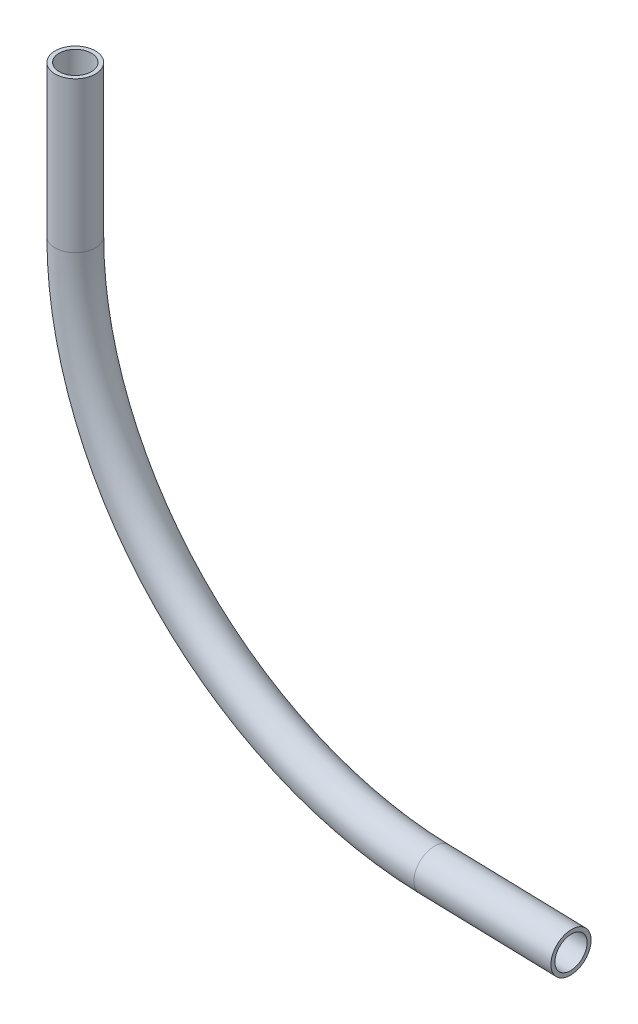
from build123d import *

# Parameters (mm, degrees)
SKETCH4_R           = 3.81
SKETCH4_R_2         = 3.048
BOSS_EXTRUDE1_DEPTH = 2.54
SKETCH4_3_R         = 3.81
SKETCH4_3_R_2       = 3.048


with BuildPart() as part:
    # Sketch4 → Boss-Extrude1 (new body)
    with BuildSketch(Plane(origin=(0, 110.370938621, 0), x_dir=(-1, 0, 0), z_dir=(0, 1, 0))):
        Circle(SKETCH4_R)
        Circle(SKETCH4_R_2, mode=Mode.SUBTRACT)
    extrude(amount=-BOSS_EXTRUDE1_DEPTH)

    # Sweep2: sweep along a path in Sketch3
    with BuildLine(Plane.XY) as sweep2_path:
        Line((0, 110.370938621), (0, 81.839949684))
        ThreePointArc((0, 81.839949684), (19.796310895, 33.11982338), (67.964229263, 12.015409809))
        Line((67.964229263, 12.015409809), (93.926499612, 11.314239564))
    # Sketch4_3 → Sweep2 (sweep)
    with BuildSketch(Plane(origin=(0, 110.370938621, 0), x_dir=(-1, 0, 0), z_dir=(0, 1, 0))):
        Circle(SKETCH4_3_R)
        Circle(SKETCH4_3_R_2, mode=Mode.SUBTRACT)
    sweep(path=sweep2_path.line)


solid = part.part
